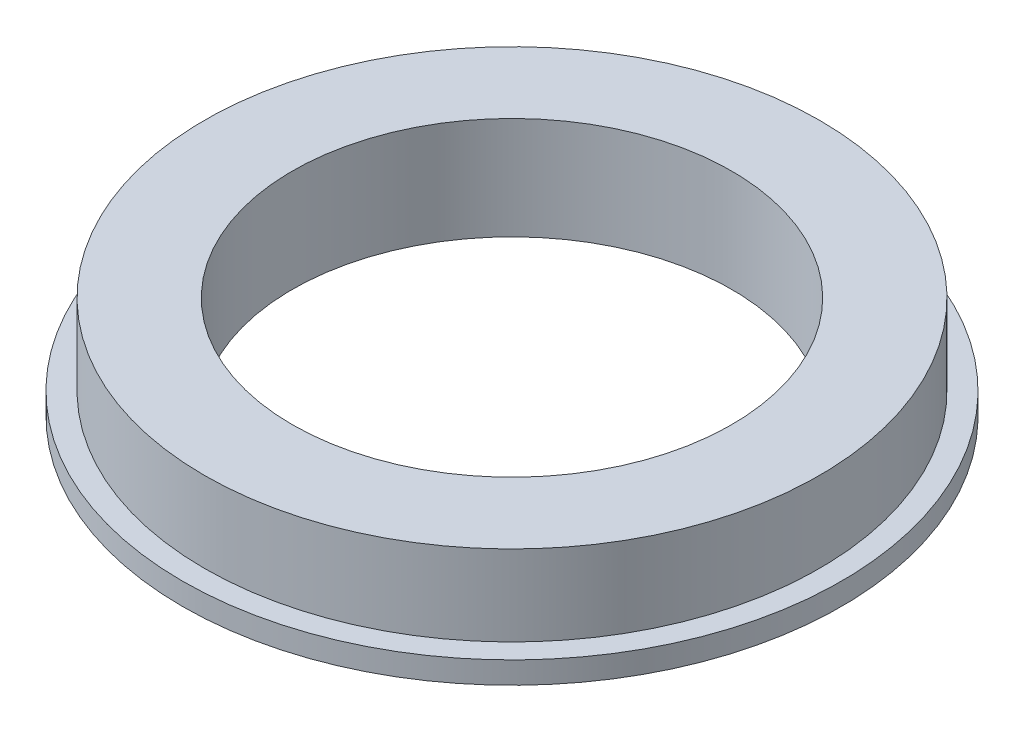
from build123d import *

# Parameters (mm, degrees)
SKETCH_1_R          = 22.5
EXTRUDE_1_DEPTH     = 1.5
SKETCH_2_R          = 21
EXTRUDE_2_DEPTH     = 5.5
SKETCH_3_R          = 15
CUT_EXTRUDE_1_DEPTH = 8


with BuildPart() as part:
    # 草图1 → 凸台-拉伸1 (new body)
    with BuildSketch(Plane(origin=(0, 0, 0), x_dir=(1, 0, 0), z_dir=(0, 1, 0))):
        Circle(SKETCH_1_R)
    extrude(amount=EXTRUDE_1_DEPTH)

    # 草图2 → 凸台-拉伸2 (add)
    with BuildSketch(Plane(origin=(0, 1.5, 0), x_dir=(1, 0, 0), z_dir=(0, 1, 0))):
        Circle(SKETCH_2_R)
    extrude(amount=EXTRUDE_2_DEPTH)

    # 草图3 → 切除-拉伸1 (cut, through all)
    with BuildSketch(Plane(origin=(0, 7, 0), x_dir=(1, 0, 0), z_dir=(0, 1, 0))):
        Circle(SKETCH_3_R)
    extrude(amount=-CUT_EXTRUDE_1_DEPTH, mode=Mode.SUBTRACT)


solid = part.part
